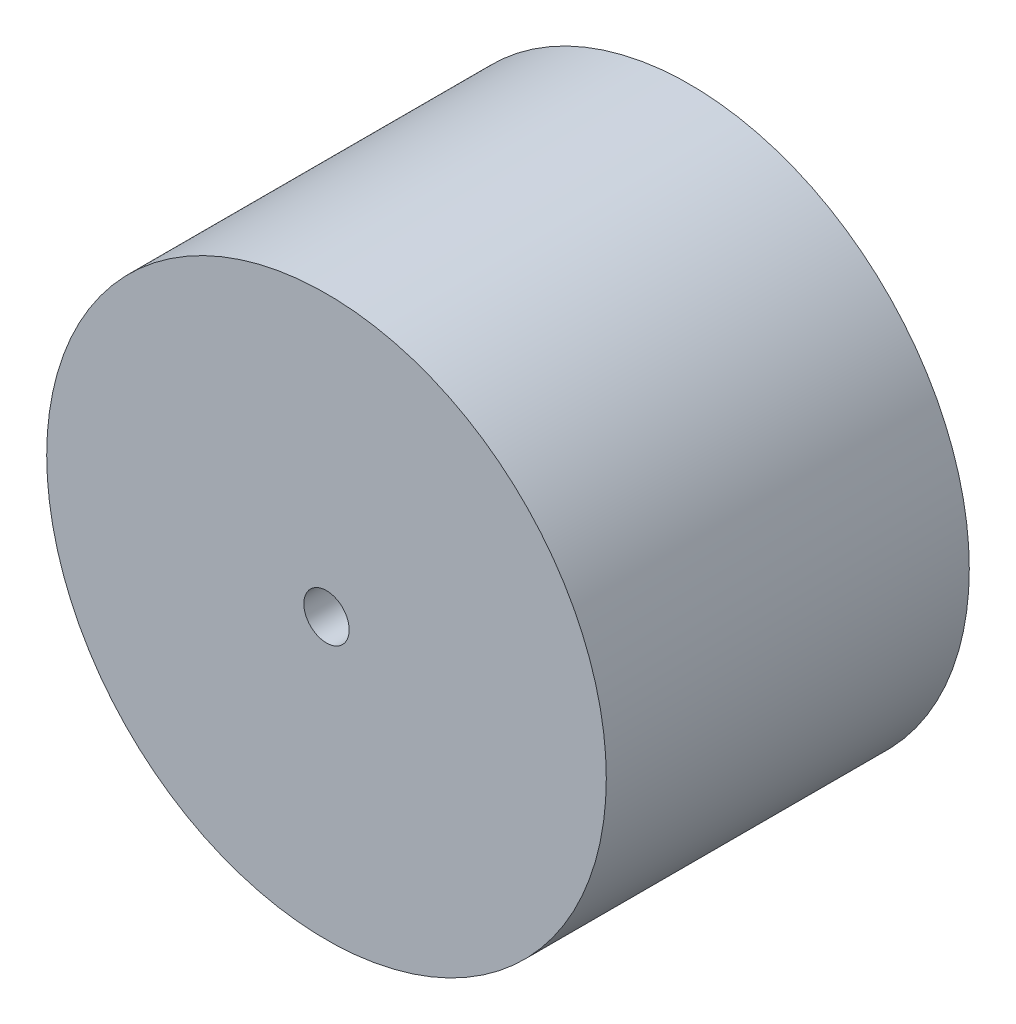
from build123d import *

# Parameters (mm, degrees)
SKETCH_1_R          = 18.5
EXTRUDE_1_DEPTH     = 24
SKETCH_2_R          = 1.5
CUT_EXTRUDE_1_DEPTH = 25


with BuildPart() as part:
    # 草图1 → 凸台-拉伸1 (new body)
    with BuildSketch(Plane.XY):
        Circle(SKETCH_1_R)
    extrude(amount=EXTRUDE_1_DEPTH)

    # 草图2 → 切除-拉伸1 (cut, through all)
    with BuildSketch(Plane.XY.offset(24)):
        Circle(SKETCH_2_R)
    extrude(amount=-CUT_EXTRUDE_1_DEPTH, mode=Mode.SUBTRACT)


solid = part.part
